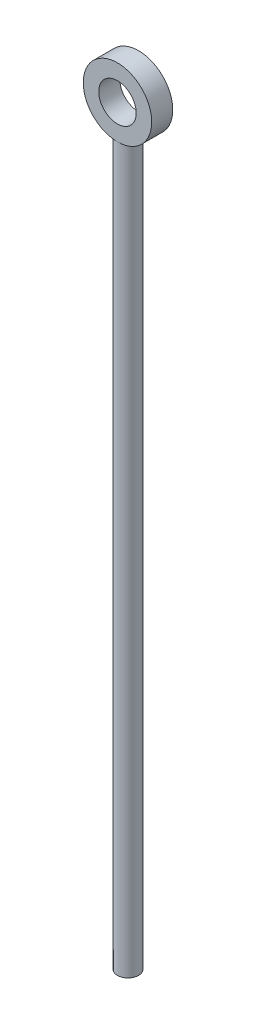
from build123d import *

# Parameters (mm, degrees)
SKETCH1_R           = 0.5
BOSS_EXTRUDE1_DEPTH = 35
SKETCH2_R           = 1.624203736
SKETCH2_R_2         = 0.889766173
BOSS_EXTRUDE2_DEPTH = 0.5


with BuildPart() as part:
    # Sketch1 → Boss-Extrude1 (new body)
    with BuildSketch(Plane(origin=(0, 0, 0), x_dir=(1, 0, 0), z_dir=(0, 1, 0))):
        Circle(SKETCH1_R)
    extrude(amount=BOSS_EXTRUDE1_DEPTH)

    # Sketch2 → Boss-Extrude2 (add, symmetric)
    with BuildSketch(Plane.XY):
        with Locations((0, 35.889766173)):
            Circle(SKETCH2_R)
        with Locations((0, 35.889766173)):
            Circle(SKETCH2_R_2, mode=Mode.SUBTRACT)
    extrude(amount=BOSS_EXTRUDE2_DEPTH, both=True)


solid = part.part
